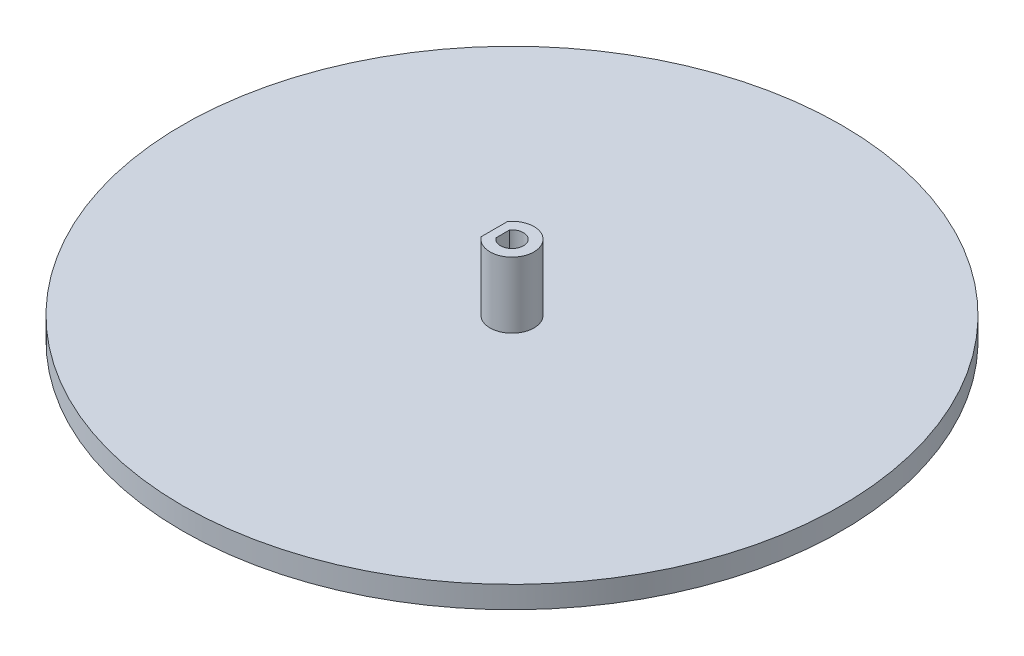
from build123d import *

# Parameters (mm, degrees)
SKETCH1_R           = 75
BOSS_EXTRUDE1_DEPTH = 5
BOSS_EXTRUDE2_DEPTH = 15


with BuildPart() as part:
    # Sketch1 → Boss-Extrude1 (new body)
    with BuildSketch(Plane(origin=(0, 0, 0), x_dir=(1, 0, 0), z_dir=(0, 1, 0))):
        Circle(SKETCH1_R)
    extrude(amount=BOSS_EXTRUDE1_DEPTH)

    # Sketch3 → Boss-Extrude2 (add)
    with BuildSketch(Plane(origin=(0, 5, 0), x_dir=(1, 0, 0), z_dir=(0, 1, 0))):
        with BuildLine():
            Line((-4, 3), (-4, -3))
            ThreePointArc((-4, -3), (5, 0), (-4, 3))
        make_face()
        with BuildLine():
            Line((-2.1, 1.532970972), (-2.1, -1.532970972))
            ThreePointArc((-2.1, -1.532970972), (2.6, 0), (-2.1, 1.532970972))
        make_face(mode=Mode.SUBTRACT)
    extrude(amount=BOSS_EXTRUDE2_DEPTH)


solid = part.part
